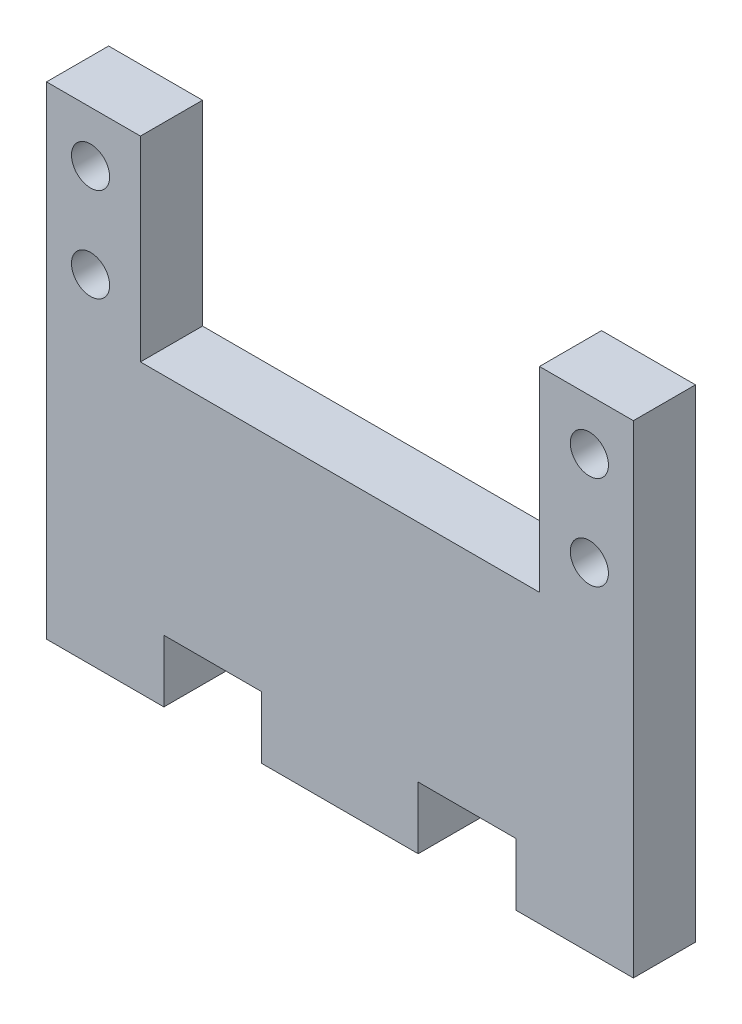
from build123d import *

# Parameters (mm, degrees)
BOSS_EXTRUDE1_DEPTH = 6.35
SKETCH2_R           = 1.95
SKETCH2_W           = 40.8
SKETCH2_H           = 20
CUT_EXTRUDE1_DEPTH  = 6.35


with BuildPart() as part:
    # Sketch1 → Boss-Extrude1 (new body)
    with BuildSketch(Plane.XY):
        Polygon((-30, -21.5), (-30, 21.5), (30, 21.5), (30, -21.5), (30, -27.85), (18, -27.85), (18, -21.5), (8, -21.5), (8, -27.85), (-8, -27.85), (-8, -21.5), (-18, -21.5), (-18, -27.85), (-30, -27.85), align=None)
    extrude(amount=BOSS_EXTRUDE1_DEPTH)

    # Sketch2 → Cut-Extrude1 (cut)
    with BuildSketch(Plane.XY.offset(6.35)):
        with Locations((-25.5, 16.3)):
            Circle(SKETCH2_R)
        with Locations((-25.5, 6.7)):
            Circle(SKETCH2_R)
        with Locations((25.5, 6.7)):
            Circle(SKETCH2_R)
        with Locations((25.5, 16.3)):
            Circle(SKETCH2_R)
        with Locations((0, 11.5)):
            Rectangle(SKETCH2_W, SKETCH2_H)
    extrude(amount=-CUT_EXTRUDE1_DEPTH, mode=Mode.SUBTRACT)


solid = part.part
